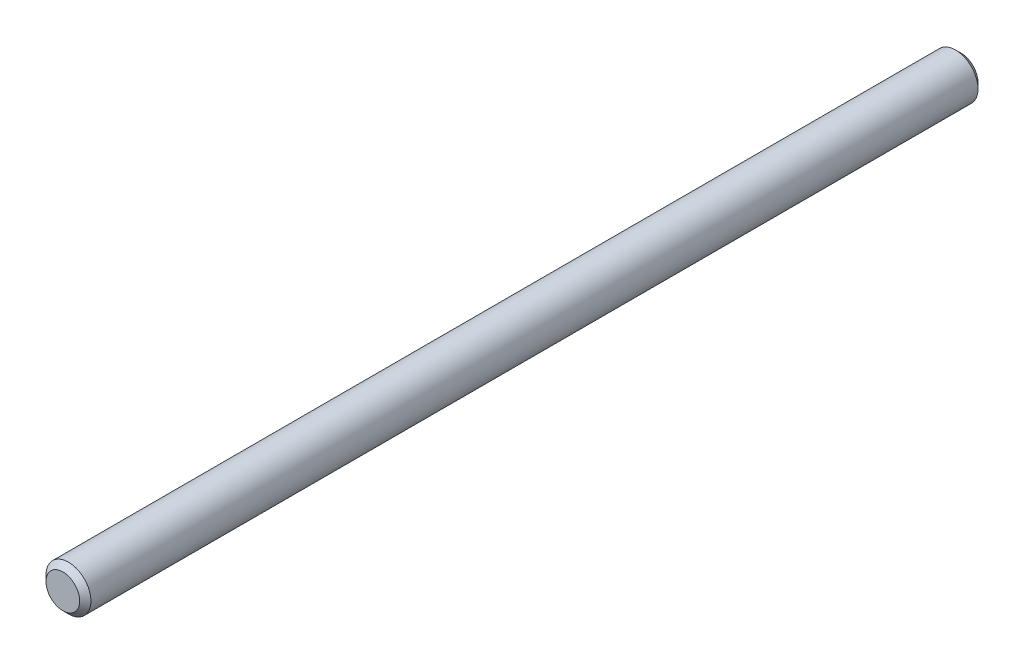
from build123d import *

# Parameters (mm, degrees)
ESBO_O1_R                = 4
RESSALTO_EXTRUS_O1_DEPTH = 160
CHANFRO1_SIZE            = 1


with BuildPart() as part:
    # Esboço1 → Ressalto-extrusão1 (new body)
    with BuildSketch(Plane.XY):
        Circle(ESBO_O1_R)
    extrude(amount=RESSALTO_EXTRUS_O1_DEPTH)

    # Chanfro1
    chanfro1_edges = [part.edges().sort_by_distance(p)[0] for p in [
        (-4, 0, 0),
        (-4, 0, 160),
    ]]
    chamfer(chanfro1_edges, length=CHANFRO1_SIZE)


solid = part.part
